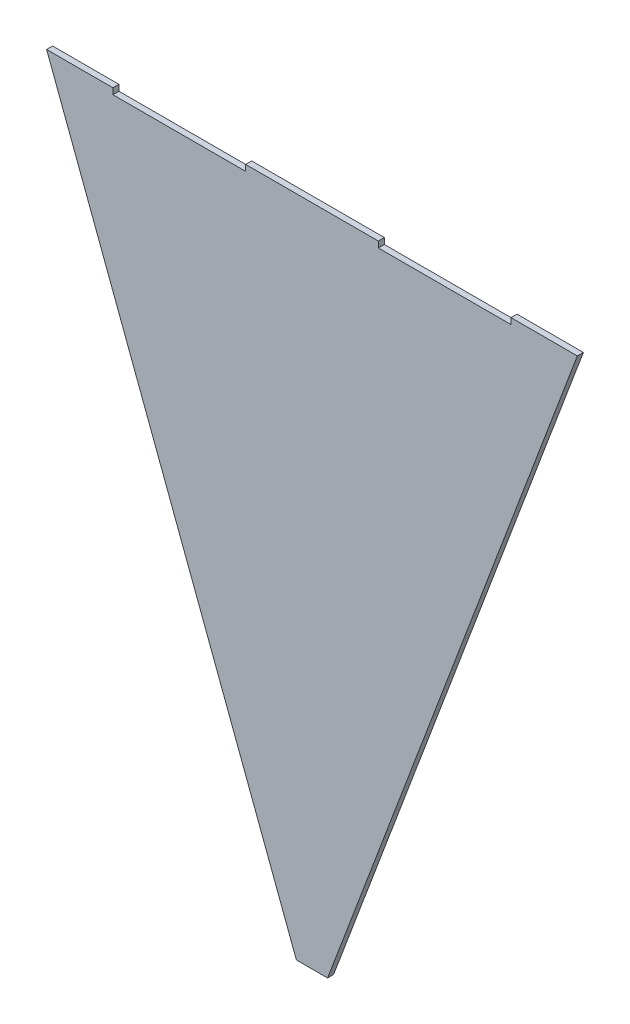
from build123d import *

# Parameters (mm, degrees)
RESSALTO_EXTRUS_O1_DEPTH = 4


with BuildPart() as part:
    # Esboço1 → Ressalto-extrusão1 (new body)
    with BuildSketch(Plane.XY):
        Polygon((176.041146015, 440.215614172), (10.35533906, 0), (-10.35533906, 0), (-176.040382005, 440.215614172), (-132.030191003, 440.215614172), (-132.030191003, 436.215614172), (-44.009808997, 436.215614172), (-44.009808997, 440.215614172), (44.009808998, 440.215614172), (44.009808998, 436.215614172), (132.030191003, 436.215614172), (132.030191003, 440.215614172), align=None)
    extrude(amount=RESSALTO_EXTRUS_O1_DEPTH)


solid = part.part
